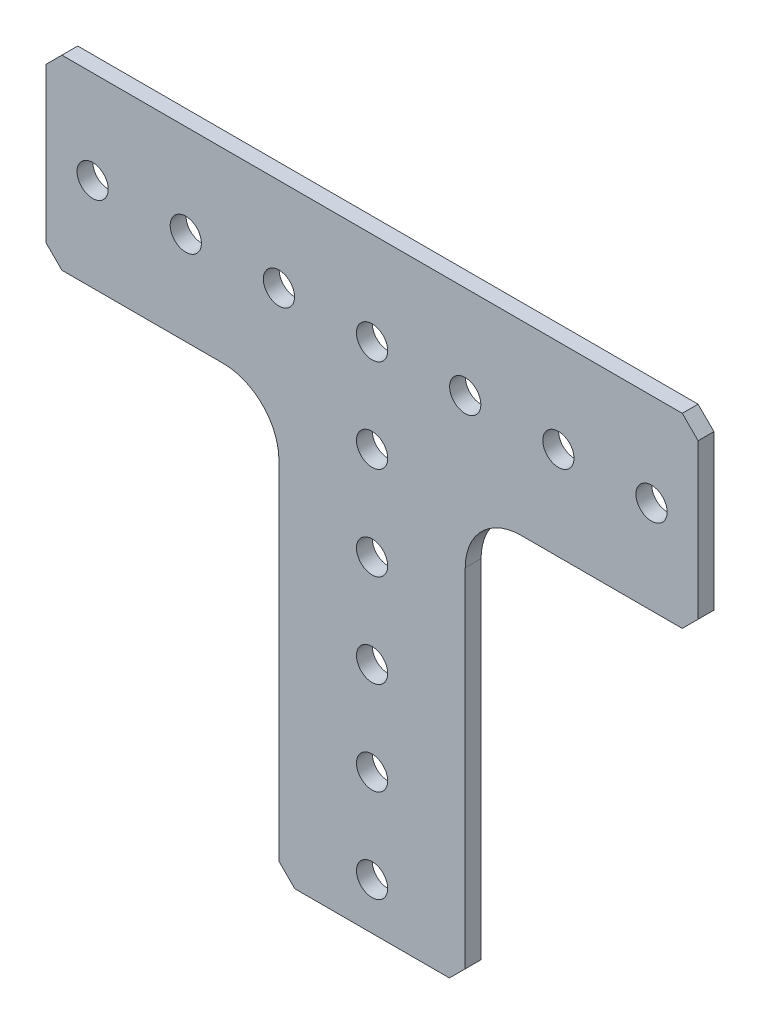
from build123d import *

# Parameters (mm, degrees)
SKETCH1_W                   = 25.4
SKETCH1_H                   = 57.15
BOSS_EXTRUDE1_DEPTH         = 2.159
FILLET1_R                   = 7.62
CHAMFER1_SIZE               = 2.159
F_1_4_0_25_DIAMETER_HOLE1_D = 4.2545


with BuildPart() as part:
    # Sketch1 → Boss-Extrude1 (new body)
    with BuildSketch(Plane.XY):
        Polygon((27.234954785, 40.570800108), (-4.515045215, 40.570800108), (-29.915045215, 40.570800108), (-61.665045215, 40.570800108), (-61.665045215, 65.970800108), (27.234954785, 65.970800108), align=None)
        with Locations((-17.215045215, 11.995800108)):
            Rectangle(SKETCH1_W, SKETCH1_H)
    extrude(amount=BOSS_EXTRUDE1_DEPTH)

    # Fillet1
    fillet1_edges = [part.edges().sort_by_distance(p)[0] for p in [
        (-4.515045215, 40.570800108, 1.0795),
        (-29.915045215, 40.570800108, 1.0795),
    ]]
    fillet(fillet1_edges, radius=FILLET1_R)

    # Chamfer1
    chamfer1_edges = [part.edges().sort_by_distance(p)[0] for p in [
        (-4.515045215, -16.579199892, 1.0795),
        (-29.915045215, -16.579199892, 1.0795),
        (-61.665045215, 40.570800108, 1.0795),
        (-61.665045215, 65.970800108, 1.0795),
        (27.234954785, 65.970800108, 1.0795),
        (27.234954785, 40.570800108, 1.0795),
    ]]
    chamfer(chamfer1_edges, length=CHAMFER1_SIZE)

    # 1/4 (0.25) Diameter Hole1 (through all)
    with Locations(Plane.XY.offset(2.159)):
        with Locations((-55.315045215, 53.270800108), (-42.615045215, 53.270800108), (-29.915045215, 53.270800108), (-17.215045215, 53.270800108), (-4.515045215, 53.270800108), (8.184954785, 53.270800108), (20.884954785, 53.270800108), (-17.215045215, 40.570800108), (-17.215045215, 27.870800108), (-17.215045215, 15.170800108), (-17.215045215, 2.470800108), (-17.215045215, -10.229199892)):
            Hole(F_1_4_0_25_DIAMETER_HOLE1_D / 2)


solid = part.part
